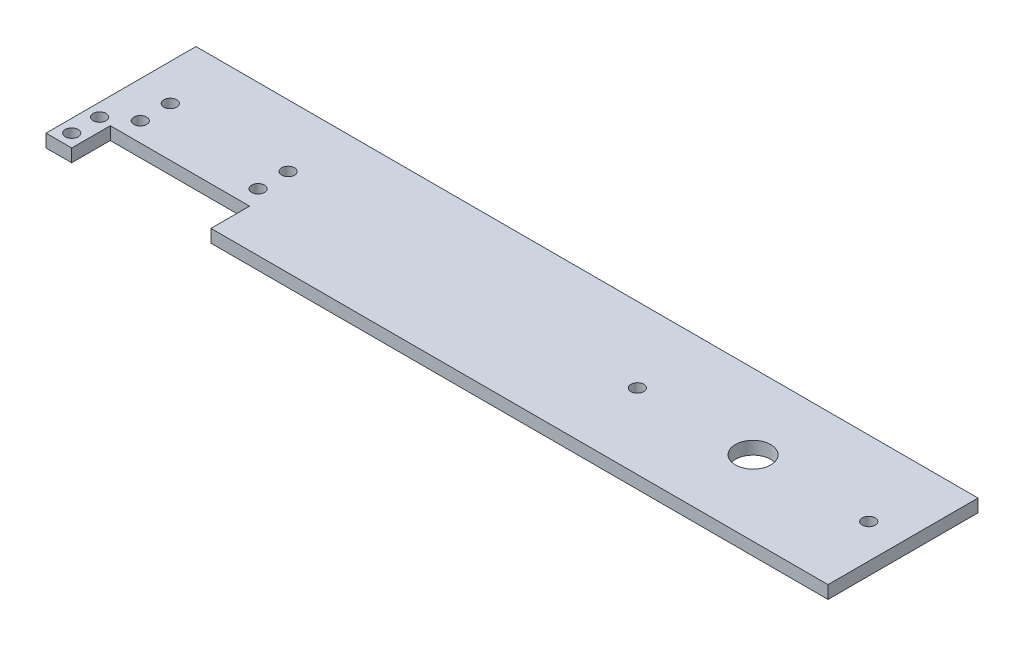
from build123d import *

# Parameters (mm, degrees)
SKETCH1_W           = 182.5
SKETCH1_H           = 35
SKETCH1_R           = 4.125
SKETCH1_R_2         = 1.5
BOSS_EXTRUDE1_DEPTH = 3
CUT_EXTRUDE3_START  = 3.5
SKETCH2_W           = 3
SKETCH2_H           = 9.897866997
SKETCH2_W_2         = 27.5
SKETCH2_W_3         = 2
CUT_EXTRUDE3_DEPTH  = 9


with BuildPart() as part:
    # Sketch1 → Boss-Extrude1 (new body)
    with BuildSketch(Plane(origin=(0, 0, 0), x_dir=(1, 0, 0), z_dir=(0, 1, 0))):
        with Locations((-8.75, 5)):
            Rectangle(SKETCH1_W, SKETCH1_H)
        with Locations((47.5, 5)):
            Circle(SKETCH1_R, mode=Mode.SUBTRACT)
        with Locations((74.5, 5)):
            Circle(SKETCH1_R_2, mode=Mode.SUBTRACT)
        with Locations((20.5, 5)):
            Circle(SKETCH1_R_2, mode=Mode.SUBTRACT)
        with Locations((-97, -9.5)):
            Circle(SKETCH1_R_2, mode=Mode.SUBTRACT)
        with Locations((-97, -3)):
            Circle(SKETCH1_R_2, mode=Mode.SUBTRACT)
        with Locations((-91.5, 8)):
            Circle(SKETCH1_R_2, mode=Mode.SUBTRACT)
        with Locations((-64, 8)):
            Circle(SKETCH1_R_2, mode=Mode.SUBTRACT)
        with Locations((-64, 1)):
            Circle(SKETCH1_R_2, mode=Mode.SUBTRACT)
        with Locations((-91.5, 1)):
            Circle(SKETCH1_R_2, mode=Mode.SUBTRACT)
    extrude(amount=BOSS_EXTRUDE1_DEPTH)

    # Sketch2 → Cut-Extrude3 (cut)
    with BuildSketch(Plane.XY.offset(CUT_EXTRUDE3_START)):
        with Locations((-90.5, 1.550857661)):
            Rectangle(SKETCH2_W, SKETCH2_H)
        with Locations((-75.25, 1.550857661)):
            Rectangle(SKETCH2_W_2, SKETCH2_H)
        with Locations((-93, 1.550857661)):
            Rectangle(SKETCH2_W_3, SKETCH2_H)
    extrude(amount=CUT_EXTRUDE3_DEPTH, mode=Mode.SUBTRACT)


solid = part.part
